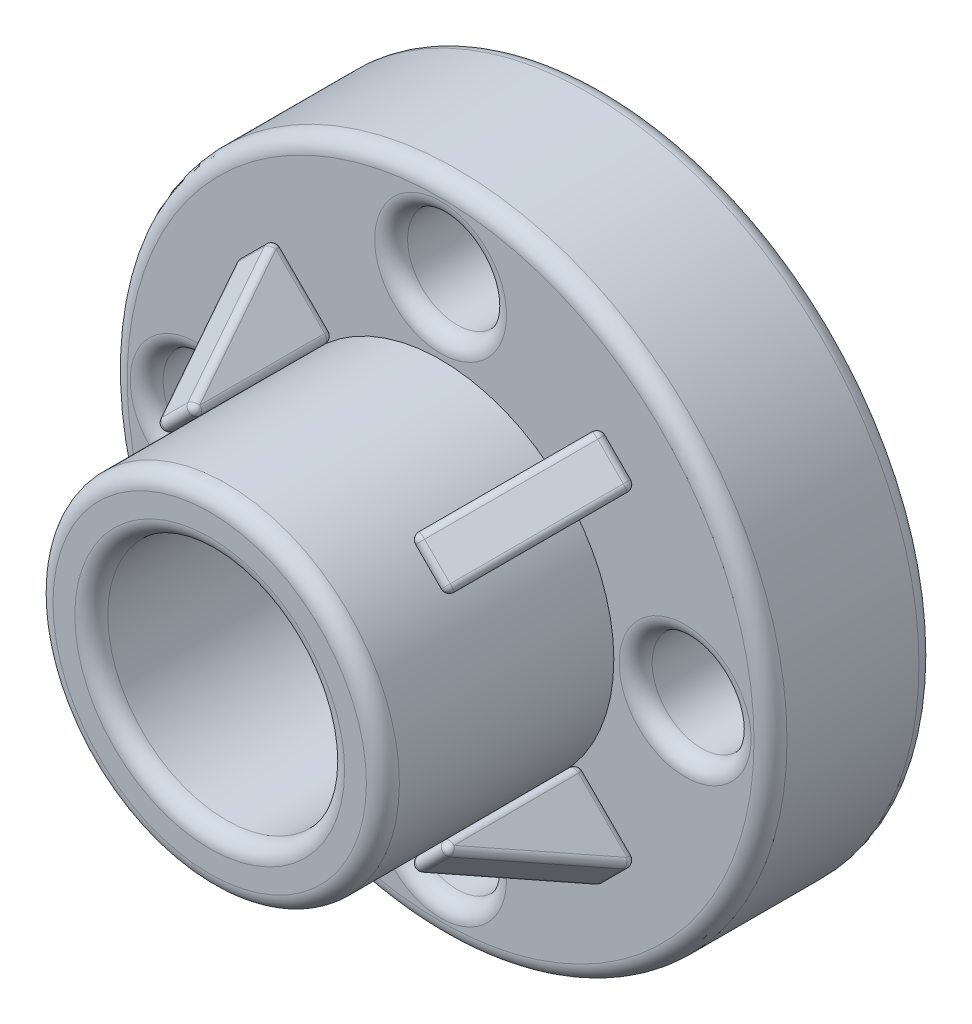
from build123d import *

# Parameters (mm, degrees)
SKETCH1_R               = 100
SKETCH1_R_2             = 15
BOSS_EXTRUDE1_DEPTH     = 50
SKETCH2_R               = 52.5
BOSS_EXTRUDE2_DEPTH     = 70
CUT_EXTRUDE1_DEPTH      = 186.47236991
CUT_EXTRUDE1_DEPTH_BACK = 186.47236991
SKETCH3_R               = 35.890783466
BOSS_EXTRUDE3_DEPTH     = 7.5
CIRPATTERN1_COUNT       = 4
FILLET1_R               = 5
FILLET2_R               = 5
FILLET3_R               = 5
FILLET4_R               = 2
FILLET5_R               = 2
FILLET6_R               = 2
FILLET7_R               = 2


with BuildPart() as part:
    # Sketch1 → Boss-Extrude1 (new body)
    with BuildSketch(Plane.XY):
        Circle(SKETCH1_R)
        with Locations((-74.109919926, 0)):
            Circle(SKETCH1_R_2, mode=Mode.SUBTRACT)
        with Locations((0, 74.109919926)):
            Circle(SKETCH1_R_2, mode=Mode.SUBTRACT)
        with Locations((74.109919926, 0)):
            Circle(SKETCH1_R_2, mode=Mode.SUBTRACT)
        with Locations((0, -74.109919926)):
            Circle(SKETCH1_R_2, mode=Mode.SUBTRACT)
    extrude(amount=BOSS_EXTRUDE1_DEPTH)

    # Sketch2 → Boss-Extrude2 (add)
    with BuildSketch(Plane.XY.offset(50)):
        Circle(SKETCH2_R)
    extrude(amount=BOSS_EXTRUDE2_DEPTH)

    # Sketch3 → Cut-Extrude1 (cut, two sides: drawn at the far end of the back side and taken through both)
    with BuildSketch(Plane.XY.offset(120).offset(-CUT_EXTRUDE1_DEPTH_BACK)):
        Circle(SKETCH3_R)
    extrude(amount=CUT_EXTRUDE1_DEPTH + CUT_EXTRUDE1_DEPTH_BACK, mode=Mode.SUBTRACT)

    # Fillet1
    fillet1_edges = [part.edges().sort_by_distance(p)[0] for p in [
        (-100, 0, 0),
        (-100, 0, 50),
    ]]
    fillet(fillet1_edges, radius=FILLET1_R)

    # Fillet2
    fillet2_edges = [part.edges().sort_by_distance(p)[0] for p in [
        (-35.890783466, 0, 120),
        (-52.5, 0, 120),
    ]]
    fillet(fillet2_edges, radius=FILLET2_R)

    # Fillet3
    fillet3_edges = [part.edges().sort_by_distance(p)[0] for p in [
        (-35.890783466, 0, 0),
        (59.109919926, 0, 0),
        (59.109919926, 0, 50),
        (-15, -74.109919926, 50),
        (-89.109919926, 0, 50),
        (-15, 74.109919926, 50),
    ]]
    fillet(fillet3_edges, radius=FILLET3_R)


with BuildPart() as body_2:
    # Sketch5 → Boss-Extrude3 (new, symmetric)
    with BuildSketch(Plane(origin=(0, 0, 0), x_dir=(0.7071067811865477, 0.7071067811865475, 0), z_dir=(-0.7071067811865475, 0.7071067811865477, 0))):
        Polygon((-52.5, -97.534110101), (-78.636621205, -50), (-52.403626933, -50), align=None)
    extrude(amount=BOSS_EXTRUDE3_DEPTH, both=True)


with BuildPart() as cirpattern1_1:
    # CirPattern1: pattern copy
    add(body_2.part.rotate(Axis((0, 0, 0), (0, 0, 1)), 1 * 360 / CIRPATTERN1_COUNT))

    # Fillet5
    fillet5_edges = [cirpattern1_1.edges().sort_by_distance(p)[0] for p in [
        (55.604488103, -55.604488103, 50),
        (41.060496199, -51.667097917, 73.76705505),
        (37.123106012, -37.123106012, 97.534110101),
        (51.667097917, -41.060496199, 73.76705505),
        (37.054959963, -37.054959963, 50),
        (41.026423174, -51.633024892, 50),
        (31.785732129, -42.392333847, 73.76705505),
        (51.633024892, -41.026423174, 50),
        (42.392333847, -31.785732129, 73.76705505),
    ]]
    fillet(fillet5_edges, radius=FILLET5_R)


with BuildPart() as cirpattern1_2:
    # CirPattern1: pattern copy
    add(body_2.part.rotate(Axis((0, 0, 0), (0, 0, 1)), 2 * 360 / CIRPATTERN1_COUNT))

    # Fillet4
    fillet4_edges = [cirpattern1_2.edges().sort_by_distance(p)[0] for p in [
        (55.604488103, 55.604488103, 50),
        (37.123106012, 37.123106012, 97.534110101),
        (41.026423174, 51.633024892, 50),
        (41.060496199, 51.667097917, 73.76705505),
        (31.785732129, 42.392333847, 73.76705505),
        (51.667097917, 41.060496199, 73.76705505),
        (51.633024892, 41.026423174, 50),
        (42.392333847, 31.785732129, 73.76705505),
    ]]
    fillet(fillet4_edges, radius=FILLET4_R)


with BuildPart() as cirpattern1_3:
    # CirPattern1: pattern copy
    add(body_2.part.rotate(Axis((0, 0, 0), (0, 0, 1)), 3 * 360 / CIRPATTERN1_COUNT))

    # Fillet7
    fillet7_edges = [cirpattern1_3.edges().sort_by_distance(p)[0] for p in [
        (-55.604488103, 55.604488103, 50),
        (-41.060496199, 51.667097917, 73.76705505),
        (-37.123106012, 37.123106012, 97.534110101),
        (-51.667097917, 41.060496199, 73.76705505),
        (-37.054959963, 37.054959963, 50),
        (-41.026423174, 51.633024892, 50),
        (-31.785732129, 42.392333847, 73.76705505),
        (-51.633024892, 41.026423174, 50),
        (-42.392333847, 31.785732129, 73.76705505),
    ]]
    fillet(fillet7_edges, radius=FILLET7_R)


with BuildPart() as body_2_1:
    add(body_2.part)

    # Fillet6
    fillet6_edges = [body_2_1.edges().sort_by_distance(p)[0] for p in [
        (-55.604488103, -55.604488103, 50),
        (-51.667097917, -41.060496199, 73.76705505),
        (-37.123106012, -37.123106012, 97.534110101),
        (-41.060496199, -51.667097917, 73.76705505),
        (-37.054959963, -37.054959963, 50),
        (-51.633024892, -41.026423174, 50),
        (-42.392333847, -31.785732129, 73.76705505),
        (-41.026423174, -51.633024892, 50),
        (-31.785732129, -42.392333847, 73.76705505),
    ]]
    fillet(fillet6_edges, radius=FILLET6_R)


solid = Compound([part.part, cirpattern1_1.part, cirpattern1_2.part, cirpattern1_3.part, body_2_1.part])
